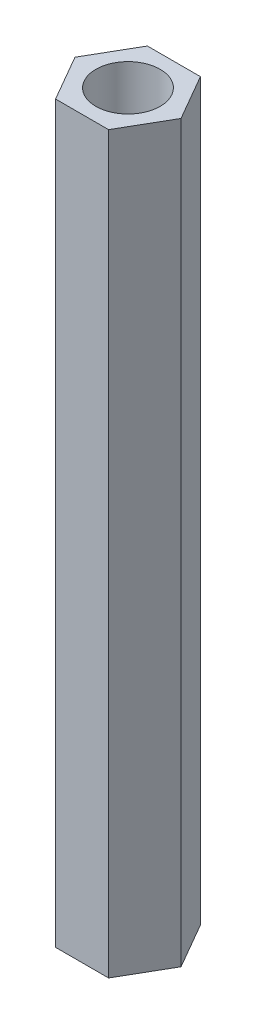
from build123d import *

# Parameters (mm, degrees)
SKETCH_1_R      = 1.75
EXTRUDE_1_DEPTH = 40


with BuildPart() as part:
    # 草圖1 → 填料-伸長1 (new body)
    with BuildSketch(Plane(origin=(0, 0, 0), x_dir=(1, 0, 0), z_dir=(0, 1, 0))):
        Polygon((2.886751346, 0), (1.443375673, 2.5), (-1.443375673, 2.5), (-2.886751346, 0), (-1.443375673, -2.5), (1.443375673, -2.5), align=None)
        Circle(SKETCH_1_R, mode=Mode.SUBTRACT)
    extrude(amount=EXTRUDE_1_DEPTH)


solid = part.part
